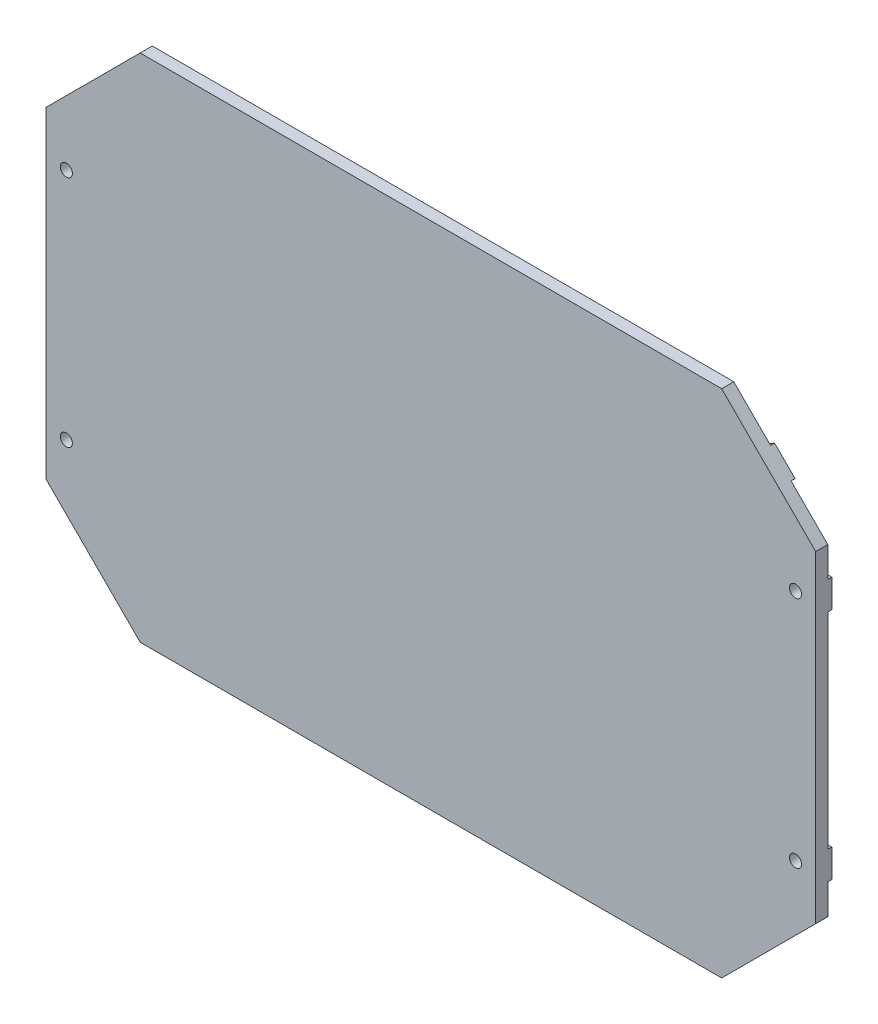
from build123d import *

# Parameters (mm, degrees)
SKETCH1_R           = 1.5
BOSS_EXTRUDE1_DEPTH = 3
SKETCH2_R           = 1.5
BOSS_EXTRUDE2_DEPTH = 1


with BuildPart() as part:
    # Sketch1 → Boss-Extrude1 (new body)
    with BuildSketch(Plane.XY):
        Polygon((-95.5, -40), (-95.5, 40), (-72.165476221, 63.334523779), (72.165476221, 63.334523779), (95.5, 40), (95.5, -40), (72.165476221, -63.334523779), (-72.165476221, -63.334523779), align=None)
        with Locations((-90.5, 29)):
            Circle(SKETCH1_R, mode=Mode.SUBTRACT)
        with Locations((-90.5, -29)):
            Circle(SKETCH1_R, mode=Mode.SUBTRACT)
        with Locations((90.5, -29)):
            Circle(SKETCH1_R, mode=Mode.SUBTRACT)
        with Locations((90.5, 29)):
            Circle(SKETCH1_R, mode=Mode.SUBTRACT)
    extrude(amount=BOSS_EXTRUDE1_DEPTH)

    # Sketch2 → Boss-Extrude2 (add)
    with BuildSketch(Plane(origin=(0, 0, 0), x_dir=(-1, 0, 0), z_dir=(0, 0, -1))):
        Polygon((-59.403736545, 32.5), (-46.062041549, 32.5), (-81.28908922, 54.21091078), (-86.376387001, 49.123612999), align=None)
        Polygon((-34.704188524, 25.5), (-46.062041549, 32.5), (-59.403736545, 32.5), (-48.045883519, 25.5), align=None)
        Polygon((-48.045883519, 25.5), (-59.403736545, 32.5), (-95.5, 32.5), (-95.5, 25.5), align=None)
        with Locations((-90.5, 29)):
            Circle(SKETCH2_R, mode=Mode.SUBTRACT)
        Polygon((34.704188524, 25.5), (46.062041549, 32.5), (-46.062041549, 32.5), (-34.704188524, 25.5), align=None)
        Polygon((59.403736545, 32.5), (46.062041549, 32.5), (34.704188524, 25.5), (48.045883519, 25.5), align=None)
        Polygon((86.376387001, 49.123612999), (81.28908922, 54.21091078), (46.062041549, 32.5), (59.403736545, 32.5), align=None)
        Polygon((95.5, 32.5), (59.403736545, 32.5), (48.045883519, 25.5), (95.5, 25.5), align=None)
        with Locations((90.5, 29)):
            Circle(SKETCH2_R, mode=Mode.SUBTRACT)
        Polygon((-6.670847498, 0), (0, 4.111334455), (-34.704188524, 25.5), (-48.045883519, 25.5), align=None)
        Polygon((48.045883519, 25.5), (34.704188524, 25.5), (0, 4.111334455), (6.670847498, 0), align=None)
        Polygon((6.670847498, 0), (0, 4.111334455), (-6.670847498, 0), (0, -4.111334455), align=None)
        Polygon((48.045883519, -25.5), (6.670847498, 0), (0, -4.111334455), (34.704188524, -25.5), align=None)
        Polygon((0, -4.111334455), (-6.670847498, 0), (-48.045883519, -25.5), (-34.704188524, -25.5), align=None)
        Polygon((-34.704188524, -25.5), (-48.045883519, -25.5), (-59.403736545, -32.5), (-46.062041549, -32.5), align=None)
        Polygon((-59.403736545, -32.5), (-48.045883519, -25.5), (-95.5, -25.5), (-95.5, -32.5), align=None)
        with Locations((-90.5, -29)):
            Circle(SKETCH2_R, mode=Mode.SUBTRACT)
        Polygon((34.704188524, -25.5), (-34.704188524, -25.5), (-46.062041549, -32.5), (46.062041549, -32.5), align=None)
        Polygon((59.403736545, -32.5), (48.045883519, -25.5), (34.704188524, -25.5), (46.062041549, -32.5), align=None)
        Polygon((95.5, -25.5), (48.045883519, -25.5), (59.403736545, -32.5), (95.5, -32.5), align=None)
        with Locations((90.5, -29)):
            Circle(SKETCH2_R, mode=Mode.SUBTRACT)
        Polygon((86.376387001, -49.123612999), (59.403736545, -32.5), (46.062041549, -32.5), (81.28908922, -54.21091078), align=None)
        Polygon((-46.062041549, -32.5), (-59.403736545, -32.5), (-86.376387001, -49.123612999), (-81.28908922, -54.21091078), align=None)
    extrude(amount=BOSS_EXTRUDE2_DEPTH)


solid = part.part
